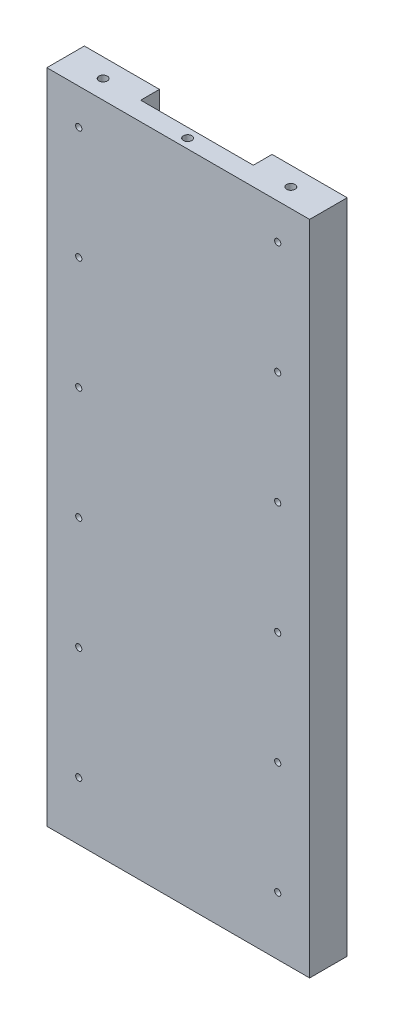
from build123d import *

# Parameters (mm, degrees)
SKETCH1_W          = 140
SKETCH1_H          = 350
EXTRUDE1_DEPTH     = 20
CUT_EXTRUDE2_DEPTH = 10
SKETCH4_R          = 2.25
CUT_EXTRUDE3_DEPTH = 15
SKETCH6_R          = 2.25
CUT_EXTRUDE5_DEPTH = 15
SKETCH7_R          = 1.65
CUT_EXTRUDE6_DEPTH = 20


with BuildPart() as part:
    # Sketch1 → Extrude1 (new body)
    with BuildSketch(Plane.XY):
        with Locations((70, 175)):
            Rectangle(SKETCH1_W, SKETCH1_H)
    extrude(amount=EXTRUDE1_DEPTH)

    # Sketch3 → Cut-Extrude2 (cut)
    with BuildSketch(Plane(origin=(0, 0, 0), x_dir=(-1, 0, 0), z_dir=(0, 0, -1))):
        Polygon((-70, 350), (-55, 350), (-40, 350), (-40, 0), (-100, 0), (-100, 350), align=None)
    extrude(amount=-CUT_EXTRUDE2_DEPTH, mode=Mode.SUBTRACT)

    # Sketch4 → Cut-Extrude3 (cut)
    with BuildSketch(Plane(origin=(0, 350, 0), x_dir=(-1, 0, 0), z_dir=(0, 1, 0))):
        with Locations((-20, 10)):
            Circle(SKETCH4_R)
        with Locations((-70, 15)):
            Circle(SKETCH4_R)
        with Locations((-120, 10)):
            Circle(SKETCH4_R)
    extrude(amount=-CUT_EXTRUDE3_DEPTH, mode=Mode.SUBTRACT)

    # Sketch6 → Cut-Extrude5 (cut)
    with BuildSketch(Plane.XZ):
        with Locations((20, 10)):
            Circle(SKETCH6_R)
        with Locations((120, 10)):
            Circle(SKETCH6_R)
    extrude(amount=-CUT_EXTRUDE5_DEPTH, mode=Mode.SUBTRACT)

    # Sketch7 → Cut-Extrude6 (cut)
    with BuildSketch(Plane(origin=(0, 0, 0), x_dir=(-1, 0, 0), z_dir=(0, 0, -1))):
        with Locations((-123, 331)):
            Circle(SKETCH7_R)
        with Locations((-17, 331)):
            Circle(SKETCH7_R)
        with Locations((-17, 31)):
            Circle(SKETCH7_R)
        with Locations((-123, 31)):
            Circle(SKETCH7_R)
        with Locations((-17, 271)):
            Circle(SKETCH7_R)
        with Locations((-17, 211)):
            Circle(SKETCH7_R)
        with Locations((-17, 151)):
            Circle(SKETCH7_R)
        with Locations((-17, 91)):
            Circle(SKETCH7_R)
        with Locations((-123, 91)):
            Circle(SKETCH7_R)
        with Locations((-123, 151)):
            Circle(SKETCH7_R)
        with Locations((-123, 211)):
            Circle(SKETCH7_R)
        with Locations((-123, 271)):
            Circle(SKETCH7_R)
    extrude(amount=-CUT_EXTRUDE6_DEPTH, mode=Mode.SUBTRACT)


solid = part.part
